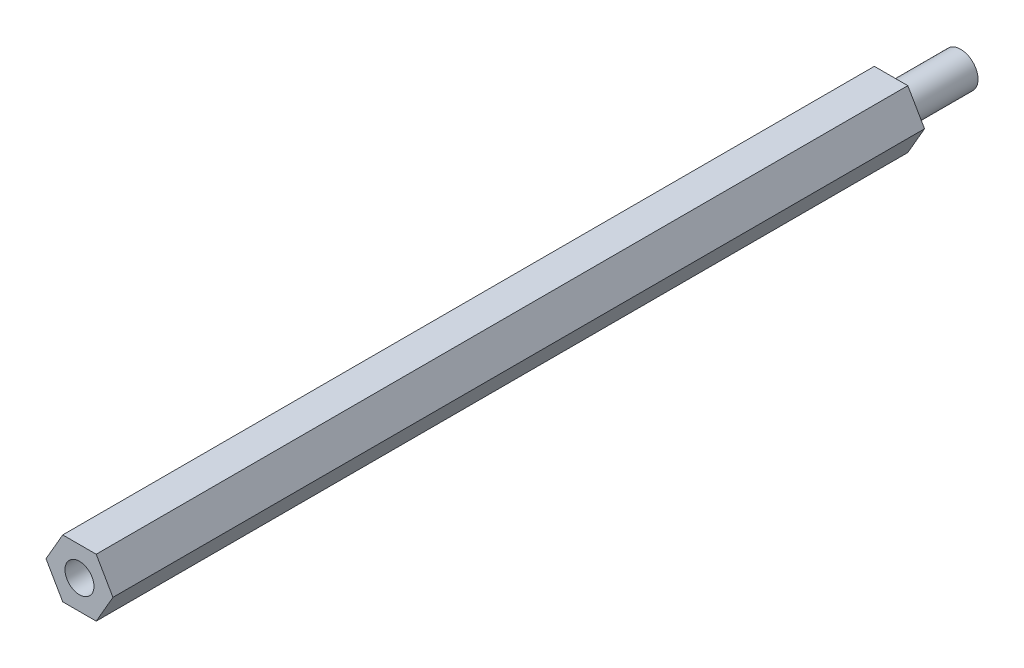
from build123d import *

# Parameters (mm, degrees)
EXTRUDE_1_DEPTH = 70
SKETCH_4_R      = 1.5
EXTRUDE_2_DEPTH = 6
M3X0_5_1_D      = 2.5
M3X0_5_1_DEPTH  = 7.5
M3X0_5_1_TIP    = 0.751075774


with BuildPart() as part:
    # 草圖1 → 填料-伸長1 (new body)
    with BuildSketch(Plane.XY):
        Polygon((-1.443375673, 2.5), (-2.886751346, 0), (-1.443375673, -2.5), (1.443375673, -2.5), (2.886751346, 0), (1.443375673, 2.5), align=None)
    extrude(amount=EXTRUDE_1_DEPTH)

    # 草圖4 → 填料-伸長2 (add)
    with BuildSketch(Plane(origin=(0, 0, 0), x_dir=(-1, 0, 0), z_dir=(0, 0, -1))):
        Circle(SKETCH_4_R)
    extrude(amount=EXTRUDE_2_DEPTH)

    # M3x0.5 螺紋孔1
    with Locations(Plane.XY.offset(70)):
        with Locations((0, 0)):
            Hole(M3X0_5_1_D / 2, depth=M3X0_5_1_DEPTH)
            with Locations((0, 0, -(M3X0_5_1_DEPTH + M3X0_5_1_TIP / 2))):  # 118° drill point
                Cone(0, M3X0_5_1_D / 2, M3X0_5_1_TIP, mode=Mode.SUBTRACT)


solid = part.part
